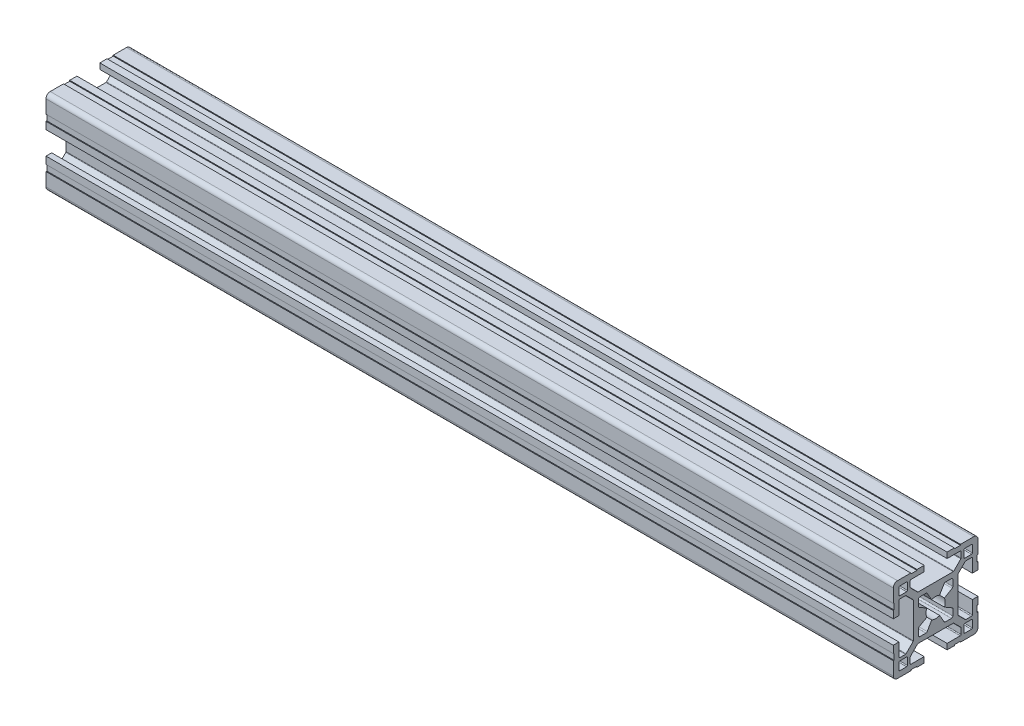
from build123d import *

# Parameters (mm, degrees)
QUADRADO_PF30_11_PERFIL_3030_CENTRO_M8_DEPTH = 300


with BuildPart() as part:
    # Sketch1 → Quadrado PF30-11 - PERFIL 3030 CENTRO M8(1) (new body)
    with BuildSketch(Plane.YZ):
        with BuildLine():
            Line((14.999995923, 6.599996803), (14.699995923, 6.599996803))
            Line((14.699995923, 6.599996803), (14.699995923, 8.799996803))
            Line((14.699995923, 8.799996803), (14.999995923, 8.799996803))
            Line((14.999995923, 8.799996803), (14.999995923, 13.499995825))
            ThreePointArc((14.999995923, 13.499995825), (14.560656066, 14.560656066), (13.499995825, 14.999995923))
            Line((13.499995825, 14.999995923), (8.799996818, 14.999995923))
            Line((8.799996818, 14.999995923), (8.799996818, 14.699995923))
            Line((8.799996818, 14.699995923), (6.599996818, 14.699995923))
            Line((6.599996818, 14.699995923), (6.599996818, 14.999995923))
            Line((6.599996818, 14.999995923), (4.0499987, 14.999995923))
            Line((4.0499987, 14.999995923), (4.0499987, 12.999995366))
            Line((4.0499987, 12.999995366), (8.699997649, 12.999995366))
            ThreePointArc((8.699997649, 12.999995366), (8.912129683, 12.9121274), (8.999997649, 12.699995366))
            Line((8.999997649, 12.699995366), (8.999997649, 10.679894006))
            ThreePointArc((8.999997649, 10.679894006), (8.977161511, 10.565088981), (8.912129691, 10.467761979))
            Line((8.912129691, 10.467761979), (6.432230191, 7.987862303))
            ThreePointArc((6.432230191, 7.987862303), (6.334903184, 7.922830472), (6.220098149, 7.89999433))
            Line((6.220098149, 7.89999433), (-6.220098149, 7.89999433))
            ThreePointArc((-6.220098149, 7.89999433), (-6.334903184, 7.922830472), (-6.432230191, 7.987862303))
            Line((-6.432230191, 7.987862303), (-8.912129691, 10.467761979))
            ThreePointArc((-8.912129691, 10.467761979), (-8.977161511, 10.565088981), (-8.999997649, 10.679894006))
            Line((-8.999997649, 10.679894006), (-8.999997649, 12.699995366))
            ThreePointArc((-8.999997649, 12.699995366), (-8.912129683, 12.9121274), (-8.699997649, 12.999995366))
            Line((-8.699997649, 12.999995366), (-4.0499987, 12.999995366))
            Line((-4.0499987, 12.999995366), (-4.0499987, 14.999995923))
            Line((-4.0499987, 14.999995923), (-6.599996818, 14.999995923))
            Line((-6.599996818, 14.999995923), (-6.599996818, 14.699995923))
            Line((-6.599996818, 14.699995923), (-8.799996818, 14.699995923))
            Line((-8.799996818, 14.699995923), (-8.799996818, 14.999995923))
            Line((-8.799996818, 14.999995923), (-13.499995825, 14.999995923))
            ThreePointArc((-13.499995825, 14.999995923), (-14.560656066, 14.560656066), (-14.999995923, 13.499995825))
            Line((-14.999995923, 13.499995825), (-14.999995923, 8.799996803))
            Line((-14.999995923, 8.799996803), (-14.699995923, 8.799996803))
            Line((-14.699995923, 8.799996803), (-14.699995923, 6.599996803))
            Line((-14.699995923, 6.599996803), (-14.999995923, 6.599996803))
            Line((-14.999995923, 6.599996803), (-14.999995923, 4.0499987))
            Line((-14.999995923, 4.0499987), (-12.999995366, 4.0499987))
            Line((-12.999995366, 4.0499987), (-12.999995366, 8.699997649))
            ThreePointArc((-12.999995366, 8.699997649), (-12.9121274, 8.912129683), (-12.699995366, 8.999997649))
            Line((-12.699995366, 8.999997649), (-10.679894006, 8.999997649))
            ThreePointArc((-10.679894006, 8.999997649), (-10.565088981, 8.977161511), (-10.467761979, 8.912129691))
            Line((-10.467761979, 8.912129691), (-7.987862303, 6.432230191))
            ThreePointArc((-7.987862303, 6.432230191), (-7.922830472, 6.334903184), (-7.89999433, 6.220098149))
            Line((-7.89999433, 6.220098149), (-7.89999433, -6.220098149))
            ThreePointArc((-7.89999433, -6.220098149), (-7.922830472, -6.334903184), (-7.987862303, -6.432230191))
            Line((-7.987862303, -6.432230191), (-10.467761979, -8.912129691))
            ThreePointArc((-10.467761979, -8.912129691), (-10.565088981, -8.977161511), (-10.679894006, -8.999997649))
            Line((-10.679894006, -8.999997649), (-12.699995366, -8.999997649))
            ThreePointArc((-12.699995366, -8.999997649), (-12.9121274, -8.912129683), (-12.999995366, -8.699997649))
            Line((-12.999995366, -8.699997649), (-12.999995366, -4.0499987))
            Line((-12.999995366, -4.0499987), (-14.999995923, -4.0499987))
            Line((-14.999995923, -4.0499987), (-14.999995923, -6.599996803))
            Line((-14.999995923, -6.599996803), (-14.699995923, -6.599996803))
            Line((-14.699995923, -6.599996803), (-14.699995923, -8.799996803))
            Line((-14.699995923, -8.799996803), (-14.999995923, -8.799996803))
            Line((-14.999995923, -8.799996803), (-14.999995923, -13.499995825))
            ThreePointArc((-14.999995923, -13.499995825), (-14.560656066, -14.560656066), (-13.499995825, -14.999995923))
            Line((-13.499995825, -14.999995923), (-8.799996818, -14.999995923))
            Line((-8.799996818, -14.999995923), (-8.799996818, -14.699995923))
            Line((-8.799996818, -14.699995923), (-6.599996818, -14.699995923))
            Line((-6.599996818, -14.699995923), (-6.599996818, -14.999995923))
            Line((-6.599996818, -14.999995923), (-4.0499987, -14.999995923))
            Line((-4.0499987, -14.999995923), (-4.0499987, -12.999995366))
            Line((-4.0499987, -12.999995366), (-8.699997649, -12.999995366))
            ThreePointArc((-8.699997649, -12.999995366), (-8.912129683, -12.9121274), (-8.999997649, -12.699995366))
            Line((-8.999997649, -12.699995366), (-8.999997649, -10.679894006))
            ThreePointArc((-8.999997649, -10.679894006), (-8.977161511, -10.565088981), (-8.912129691, -10.467761979))
            Line((-8.912129691, -10.467761979), (-6.432230191, -7.987862303))
            ThreePointArc((-6.432230191, -7.987862303), (-6.334903184, -7.922830472), (-6.220098149, -7.89999433))
            Line((-6.220098149, -7.89999433), (6.220098149, -7.89999433))
            ThreePointArc((6.220098149, -7.89999433), (6.334903184, -7.922830472), (6.432230191, -7.987862303))
            Line((6.432230191, -7.987862303), (8.912129691, -10.467761979))
            ThreePointArc((8.912129691, -10.467761979), (8.977161511, -10.565088981), (8.999997649, -10.679894006))
            Line((8.999997649, -10.679894006), (8.999997649, -12.699995366))
            ThreePointArc((8.999997649, -12.699995366), (8.912129683, -12.9121274), (8.699997649, -12.999995366))
            Line((8.699997649, -12.999995366), (4.0499987, -12.999995366))
            Line((4.0499987, -12.999995366), (4.0499987, -14.999995923))
            Line((4.0499987, -14.999995923), (6.599996818, -14.999995923))
            Line((6.599996818, -14.999995923), (6.599996818, -14.699995923))
            Line((6.599996818, -14.699995923), (8.799996818, -14.699995923))
            Line((8.799996818, -14.699995923), (8.799996818, -14.999995923))
            Line((8.799996818, -14.999995923), (13.499995825, -14.999995923))
            ThreePointArc((13.499995825, -14.999995923), (14.560656066, -14.560656066), (14.999995923, -13.499995825))
            Line((14.999995923, -13.499995825), (14.999995923, -8.799996803))
            Line((14.999995923, -8.799996803), (14.699995923, -8.799996803))
            Line((14.699995923, -8.799996803), (14.699995923, -6.599996803))
            Line((14.699995923, -6.599996803), (14.999995923, -6.599996803))
            Line((14.999995923, -6.599996803), (14.999995923, -4.0499987))
            Line((14.999995923, -4.0499987), (12.999995366, -4.0499987))
            Line((12.999995366, -4.0499987), (12.999995366, -8.699997649))
            ThreePointArc((12.999995366, -8.699997649), (12.9121274, -8.912129683), (12.699995366, -8.999997649))
            Line((12.699995366, -8.999997649), (10.679894006, -8.999997649))
            ThreePointArc((10.679894006, -8.999997649), (10.565088981, -8.977161511), (10.467761979, -8.912129691))
            Line((10.467761979, -8.912129691), (7.987862303, -6.432230191))
            ThreePointArc((7.987862303, -6.432230191), (7.922830472, -6.334903184), (7.89999433, -6.220098149))
            Line((7.89999433, -6.220098149), (7.89999433, 6.220098149))
            ThreePointArc((7.89999433, 6.220098149), (7.922830472, 6.334903184), (7.987862303, 6.432230191))
            Line((7.987862303, 6.432230191), (10.467761979, 8.912129691))
            ThreePointArc((10.467761979, 8.912129691), (10.565088981, 8.977161511), (10.679894006, 8.999997649))
            Line((10.679894006, 8.999997649), (12.699995366, 8.999997649))
            ThreePointArc((12.699995366, 8.999997649), (12.9121274, 8.912129683), (12.999995366, 8.699997649))
            Line((12.999995366, 8.699997649), (12.999995366, 4.0499987))
            Line((12.999995366, 4.0499987), (14.999995923, 4.0499987))
            Line((14.999995923, 4.0499987), (14.999995923, 6.599996803))
        make_face()
        with BuildLine():
            Line((-6.1, -3.425408784), (-6.1, -5.6))
            ThreePointArc((-6.1, -5.6), (-5.953553391, -5.953553391), (-5.6, -6.1))
            Line((-5.6, -6.1), (-3.425408784, -6.1))
            ThreePointArc((-3.425408784, -6.1), (-3.175408784, -6.033012702), (-2.992396082, -5.85))
            Line((-2.992396082, -5.85), (-1.402974441, -3.097040962))
            ThreePointArc((-1.402974441, -3.097040962), (0, -3.4), (1.402974441, -3.097040962))
            Line((1.402974441, -3.097040962), (2.992396082, -5.85))
            ThreePointArc((2.992396082, -5.85), (3.175408784, -6.033012702), (3.425408784, -6.1))
            Line((3.425408784, -6.1), (5.6, -6.1))
            ThreePointArc((5.6, -6.1), (5.953553391, -5.953553391), (6.1, -5.6))
            Line((6.1, -5.6), (6.1, -3.425408784))
            ThreePointArc((6.1, -3.425408784), (6.033012702, -3.175408784), (5.85, -2.992396082))
            Line((5.85, -2.992396082), (3.097040962, -1.402974441))
            ThreePointArc((3.097040962, -1.402974441), (3.4, 0), (3.097040962, 1.402974441))
            Line((3.097040962, 1.402974441), (5.85, 2.992396082))
            ThreePointArc((5.85, 2.992396082), (6.033012702, 3.175408784), (6.1, 3.425408784))
            Line((6.1, 3.425408784), (6.1, 5.6))
            ThreePointArc((6.1, 5.6), (5.953553391, 5.953553391), (5.6, 6.1))
            Line((5.6, 6.1), (3.425408784, 6.1))
            ThreePointArc((3.425408784, 6.1), (3.175408784, 6.033012702), (2.992396082, 5.85))
            Line((2.992396082, 5.85), (1.402974441, 3.097040962))
            ThreePointArc((1.402974441, 3.097040962), (0, 3.4), (-1.402974441, 3.097040962))
            Line((-1.402974441, 3.097040962), (-2.992396082, 5.85))
            ThreePointArc((-2.992396082, 5.85), (-3.175408784, 6.033012702), (-3.425408784, 6.1))
            Line((-3.425408784, 6.1), (-5.6, 6.1))
            ThreePointArc((-5.6, 6.1), (-5.953553391, 5.953553391), (-6.1, 5.6))
            Line((-6.1, 5.6), (-6.1, 3.425408784))
            ThreePointArc((-6.1, 3.425408784), (-6.033012702, 3.175408784), (-5.85, 2.992396082))
            Line((-5.85, 2.992396082), (-3.097040962, 1.402974441))
            ThreePointArc((-3.097040962, 1.402974441), (-3.4, 0), (-3.097040962, -1.402974441))
            Line((-3.097040962, -1.402974441), (-5.85, -2.992396082))
            ThreePointArc((-5.85, -2.992396082), (-6.033012702, -3.175408784), (-6.1, -3.425408784))
        make_face(mode=Mode.SUBTRACT)
        with BuildLine():
            Line((9.999995366, 12.699997649), (9.999995366, 10.299997649))
            ThreePointArc((9.999995366, 10.299997649), (10.087863331, 10.087865615), (10.299995366, 9.999997649))
            Line((10.299995366, 9.999997649), (12.699995366, 9.999997649))
            ThreePointArc((12.699995366, 9.999997649), (12.9121274, 10.087865615), (12.999995366, 10.299997649))
            Line((12.999995366, 10.299997649), (12.999995366, 12.699997649))
            ThreePointArc((12.999995366, 12.699997649), (12.9121274, 12.912129683), (12.699995366, 12.999997649))
            Line((12.699995366, 12.999997649), (10.299995366, 12.999997649))
            ThreePointArc((10.299995366, 12.999997649), (10.087863331, 12.912129683), (9.999995366, 12.699997649))
        make_face(mode=Mode.SUBTRACT)
        with BuildLine():
            Line((12.999995366, -12.699997649), (12.999995366, -10.299997649))
            ThreePointArc((12.999995366, -10.299997649), (12.9121274, -10.087865615), (12.699995366, -9.999997649))
            Line((12.699995366, -9.999997649), (10.299995366, -9.999997649))
            ThreePointArc((10.299995366, -9.999997649), (10.087863331, -10.087865615), (9.999995366, -10.299997649))
            Line((9.999995366, -10.299997649), (9.999995366, -12.699997649))
            ThreePointArc((9.999995366, -12.699997649), (10.087863331, -12.912129683), (10.299995366, -12.999997649))
            Line((10.299995366, -12.999997649), (12.699995366, -12.999997649))
            ThreePointArc((12.699995366, -12.999997649), (12.9121274, -12.912129683), (12.999995366, -12.699997649))
        make_face(mode=Mode.SUBTRACT)
        with BuildLine():
            Line((-10.299995366, -9.999997649), (-12.699995366, -9.999997649))
            ThreePointArc((-12.699995366, -9.999997649), (-12.9121274, -10.087865615), (-12.999995366, -10.299997649))
            Line((-12.999995366, -10.299997649), (-12.999995366, -12.699997649))
            ThreePointArc((-12.999995366, -12.699997649), (-12.9121274, -12.912129683), (-12.699995366, -12.999997649))
            Line((-12.699995366, -12.999997649), (-10.299995366, -12.999997649))
            ThreePointArc((-10.299995366, -12.999997649), (-10.087863331, -12.912129683), (-9.999995366, -12.699997649))
            Line((-9.999995366, -12.699997649), (-9.999995366, -10.299997649))
            ThreePointArc((-9.999995366, -10.299997649), (-10.087863331, -10.087865615), (-10.299995366, -9.999997649))
        make_face(mode=Mode.SUBTRACT)
        with BuildLine():
            Line((-12.999995366, 12.699997649), (-12.999995366, 10.299997649))
            ThreePointArc((-12.999995366, 10.299997649), (-12.9121274, 10.087865615), (-12.699995366, 9.999997649))
            Line((-12.699995366, 9.999997649), (-10.299995366, 9.999997649))
            ThreePointArc((-10.299995366, 9.999997649), (-10.087863331, 10.087865615), (-9.999995366, 10.299997649))
            Line((-9.999995366, 10.299997649), (-9.999995366, 12.699997649))
            ThreePointArc((-9.999995366, 12.699997649), (-10.087863331, 12.912129683), (-10.299995366, 12.999997649))
            Line((-10.299995366, 12.999997649), (-12.699995366, 12.999997649))
            ThreePointArc((-12.699995366, 12.999997649), (-12.9121274, 12.912129683), (-12.999995366, 12.699997649))
        make_face(mode=Mode.SUBTRACT)
    extrude(amount=QUADRADO_PF30_11_PERFIL_3030_CENTRO_M8_DEPTH)


solid = part.part
